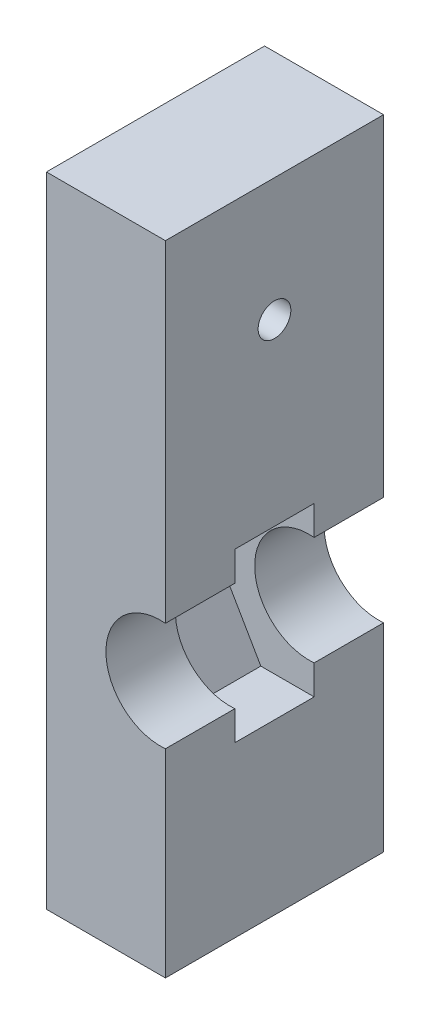
from build123d import *

# Parameters (mm, degrees)
SKETCH_1_W          = 23
SKETCH_1_H          = 64.4
EXTRUDE_1_DEPTH     = 8
SKETCH_3_W          = 23
SKETCH_3_H          = 64.4
SKETCH_3_R          = 5.5
EXTRUDE_2_DEPTH     = 7
SKETCH_4_W          = 23
SKETCH_4_H          = 64.4
SKETCH_4_R          = 5.5
EXTRUDE_3_DEPTH     = 7
SKETCH_5_R          = 1.65
CUT_EXTRUDE_1_DEPTH = 24
SKETCH_6_W          = 22
SKETCH_6_H          = 64.4
CUT_EXTRUDE_2_DEPTH = 11


with BuildPart() as part:
    # 草圖1 → 填料-伸長1 (new body)
    with BuildSketch(Plane.XY):
        with Locations((-0.36746988, -27.579314659)):
            Rectangle(SKETCH_1_W, SKETCH_1_H)
        Polygon((9.38974967, -34.279314659), (4.511139895, -25.829314659), (-5.246079654, -25.829314659), (-10.124689429, -34.279314659), (-5.246079654, -42.729314659), (4.511139895, -42.729314659), align=None, mode=Mode.SUBTRACT)
    extrude(amount=EXTRUDE_1_DEPTH)

    # 草圖3 → 填料-伸長2 (add)
    with BuildSketch(Plane.XY.offset(8)):
        with Locations((-0.36746988, -27.579314659)):
            Rectangle(SKETCH_3_W, SKETCH_3_H)
        with Locations((-0.36746988, -34.279314659)):
            Circle(SKETCH_3_R, mode=Mode.SUBTRACT)
    extrude(amount=EXTRUDE_2_DEPTH)

    # 草圖4 → 填料-伸長3 (add)
    with BuildSketch(Plane(origin=(0, 0, 0), x_dir=(-1, 0, 0), z_dir=(0, 0, -1))):
        with Locations((0.36746988, -27.579314659)):
            Rectangle(SKETCH_4_W, SKETCH_4_H)
        with Locations((0.36746988, -34.279314659)):
            Circle(SKETCH_4_R, mode=Mode.SUBTRACT)
    extrude(amount=EXTRUDE_3_DEPTH)

    # 草圖5 → 除料-伸長1 (cut, through all)
    with BuildSketch(Plane(origin=(11.13253012, 0, 0), x_dir=(0, 0, -1), z_dir=(1, 0, 0))):
        with Locations((-4, -7.779314659)):
            Circle(SKETCH_5_R)
    extrude(amount=-CUT_EXTRUDE_1_DEPTH, mode=Mode.SUBTRACT)

    # 草圖6 → 除料-伸長2 (cut)
    with BuildSketch(Plane(origin=(11.13253012, 0, 0), x_dir=(0, 0, -1), z_dir=(1, 0, 0))):
        with Locations((-4, -27.579314659)):
            Rectangle(SKETCH_6_W, SKETCH_6_H)
    extrude(amount=-CUT_EXTRUDE_2_DEPTH, mode=Mode.SUBTRACT)


solid = part.part
